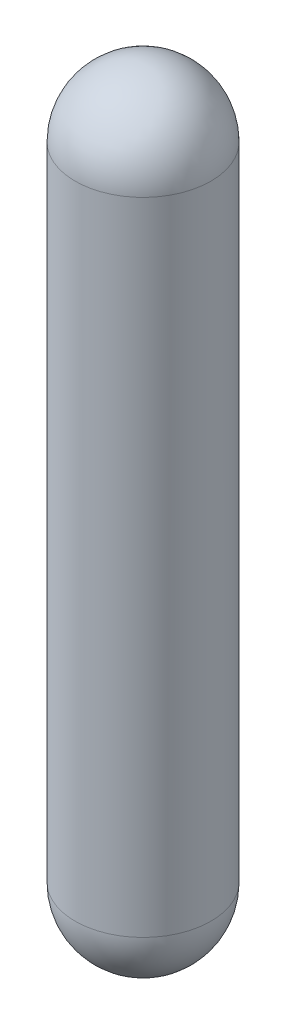
from build123d import *


with BuildPart() as part:
    # Sketch1 → Revolve1 (revolve)
    with BuildSketch(Plane.XY, mode=Mode.PRIVATE) as revolve1_sk:
        with BuildLine():
            Line((9.048261382, 85.383567839), (9.048261382, 0))
            ThreePointArc((9.048261382, 0), (6.398086981, -6.398086981), (0, -9.048261382))
            Line((0, -9.048261382), (0, 94.431829221))
            ThreePointArc((0, 94.431829221), (6.398086981, 91.78165482), (9.048261382, 85.383567839))
        make_face()
    revolve(revolve1_sk.sketch.rotate(Axis((0, 0, 0), (0, 1, 0)), 90), axis=Axis((0, 0, 0), (0, 1, 0)))  # turned: the seam where the file's is


solid = part.part
